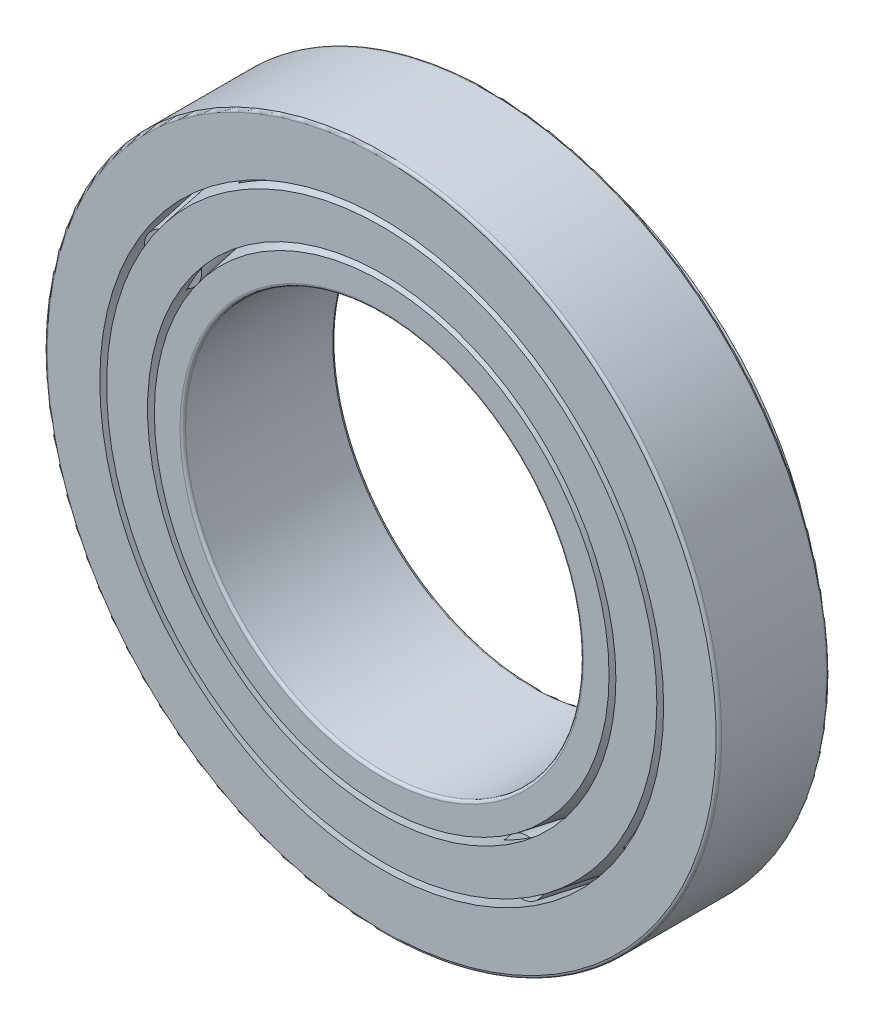
from build123d import *

# Parameters (mm, degrees)
CIRPATTERN1_COUNT = 12
CIRPATTERN2_COUNT = 12
CIRPATTERN2_ANGLE = 330
FILLET1_R         = 0.396875
FILLET2_R         = 0.396875


with BuildPart() as part:
    # Sketch1 → Revolve1 (revolve)
    with BuildSketch(Plane(origin=(0, 0, 0), x_dir=(0, 0, -1), z_dir=(1, 0, 0))):
        Polygon((-10.9728, 48.41875), (4.9022, 48.41875), (4.9022, 43.280440819), (-10.9728, 40.48125), align=None)
    revolve(axis=Axis((0, 0, 10.9728), (0, 0, -1)))

    # Fillet1
    fillet1_edges = [part.edges().sort_by_distance(p)[0] for p in [
        (0, -48.41875, -4.9022),
        (0, -48.41875, 10.9728),
    ]]
    fillet(fillet1_edges, radius=FILLET1_R)


with BuildPart() as body_2:
    # Sketch5 → Revolve4 (revolve)
    with BuildSketch(Plane(origin=(0, 0, 0), x_dir=(0, 0, -1), z_dir=(1, 0, 0))):
        Polygon((10.9728, 36.5125), (-10.9728, 32.642898612), (-10.9728, 28.575), (10.9728, 28.575), align=None)
    revolve(axis=Axis((0, 0, 10.9728), (0, 0, -1)))

    # Fillet2
    fillet2_edges = [body_2.edges().sort_by_distance(p)[0] for p in [
        (0, -28.575, 10.9728),
        (0, -28.575, -10.9728),
    ]]
    fillet(fillet2_edges, radius=FILLET2_R)


with BuildPart() as body_3:
    # Sketch2 → Revolve2 (revolve)
    with BuildSketch(Plane(origin=(0, 0, 0), x_dir=(0, 0, -1), z_dir=(1, 0, 0))):
        Polygon((-10.9728, 39.501456077), (-10.9728, 33.622692536), (4.9022, 36.421883354), (9.860365371, 37.296141684), (8.855037597, 42.997638814), (4.9022, 42.300646895), align=None)
    revolve(axis=Axis((0, 0, 10.9728), (0, 0, -1)))

    # Sketch3 → Cut-Revolve1 (revolve, cut)
    with BuildSketch(Plane(origin=(0, 0, 0), x_dir=(0, 0, -1), z_dir=(1, 0, 0))):
        Polygon((-8.962144451, 36.916607128), (-9.632362967, 40.717605215), (4.231981484, 43.162263211), (4.9022, 39.361265125), align=None)
    cut_revolve1 = revolve(axis=Axis((0, 36.562074306, 10.9728), (0, 0.173648178, -0.984807753)), mode=Mode.SUBTRACT)

    # CirPattern1: Cut-Revolve1 ×12 about axis
    cirpattern1_axis = Axis((0, 0, 0), (0, 0, 1))
    for i in range(1, CIRPATTERN1_COUNT):
        add(cut_revolve1.rotate(cirpattern1_axis, i * 360 / CIRPATTERN1_COUNT), mode=Mode.SUBTRACT)


with BuildPart() as body_4:
    # Sketch4 → Revolve3 (revolve)
    with BuildSketch(Plane(origin=(0, 0, 0), x_dir=(0, 0, -1), z_dir=(1, 0, 0))):
        Polygon((-9.58825633, 40.467464046), (4.276088121, 42.912122042), (4.9022, 39.361265125), (-8.962144451, 36.916607128), align=None)
    revolve(axis=Axis((0, 36.562074306, 10.9728), (0, 0.173648178, -0.984807753)))


with BuildPart() as cirpattern2_1:
    # CirPattern2: pattern copy
    add(body_4.part.rotate(Axis((0, 0, -10.9728), (0, 0, 1)), 1 * CIRPATTERN2_ANGLE / (CIRPATTERN2_COUNT - 1)))


with BuildPart() as cirpattern2_2:
    # CirPattern2: pattern copy
    add(body_4.part.rotate(Axis((0, 0, -10.9728), (0, 0, 1)), 2 * CIRPATTERN2_ANGLE / (CIRPATTERN2_COUNT - 1)))


with BuildPart() as cirpattern2_3:
    # CirPattern2: pattern copy
    add(body_4.part.rotate(Axis((0, 0, -10.9728), (0, 0, 1)), 3 * CIRPATTERN2_ANGLE / (CIRPATTERN2_COUNT - 1)))


with BuildPart() as cirpattern2_4:
    # CirPattern2: pattern copy
    add(body_4.part.rotate(Axis((0, 0, -10.9728), (0, 0, 1)), 4 * CIRPATTERN2_ANGLE / (CIRPATTERN2_COUNT - 1)))


with BuildPart() as cirpattern2_5:
    # CirPattern2: pattern copy
    add(body_4.part.rotate(Axis((0, 0, -10.9728), (0, 0, 1)), 5 * CIRPATTERN2_ANGLE / (CIRPATTERN2_COUNT - 1)))


with BuildPart() as cirpattern2_6:
    # CirPattern2: pattern copy
    add(body_4.part.rotate(Axis((0, 0, -10.9728), (0, 0, 1)), 6 * CIRPATTERN2_ANGLE / (CIRPATTERN2_COUNT - 1)))


with BuildPart() as cirpattern2_7:
    # CirPattern2: pattern copy
    add(body_4.part.rotate(Axis((0, 0, -10.9728), (0, 0, 1)), 7 * CIRPATTERN2_ANGLE / (CIRPATTERN2_COUNT - 1)))


with BuildPart() as cirpattern2_8:
    # CirPattern2: pattern copy
    add(body_4.part.rotate(Axis((0, 0, -10.9728), (0, 0, 1)), 8 * CIRPATTERN2_ANGLE / (CIRPATTERN2_COUNT - 1)))


with BuildPart() as cirpattern2_9:
    # CirPattern2: pattern copy
    add(body_4.part.rotate(Axis((0, 0, -10.9728), (0, 0, 1)), 9 * CIRPATTERN2_ANGLE / (CIRPATTERN2_COUNT - 1)))


with BuildPart() as cirpattern2_10:
    # CirPattern2: pattern copy
    add(body_4.part.rotate(Axis((0, 0, -10.9728), (0, 0, 1)), 10 * CIRPATTERN2_ANGLE / (CIRPATTERN2_COUNT - 1)))


with BuildPart() as cirpattern2_11:
    # CirPattern2: pattern copy
    add(body_4.part.rotate(Axis((0, 0, -10.9728), (0, 0, 1)), 11 * CIRPATTERN2_ANGLE / (CIRPATTERN2_COUNT - 1)))


solid = Compound([part.part, body_2.part, body_3.part, body_4.part, cirpattern2_1.part, cirpattern2_2.part, cirpattern2_3.part, cirpattern2_4.part, cirpattern2_5.part, cirpattern2_6.part, cirpattern2_7.part, cirpattern2_8.part, cirpattern2_9.part, cirpattern2_10.part, cirpattern2_11.part])
